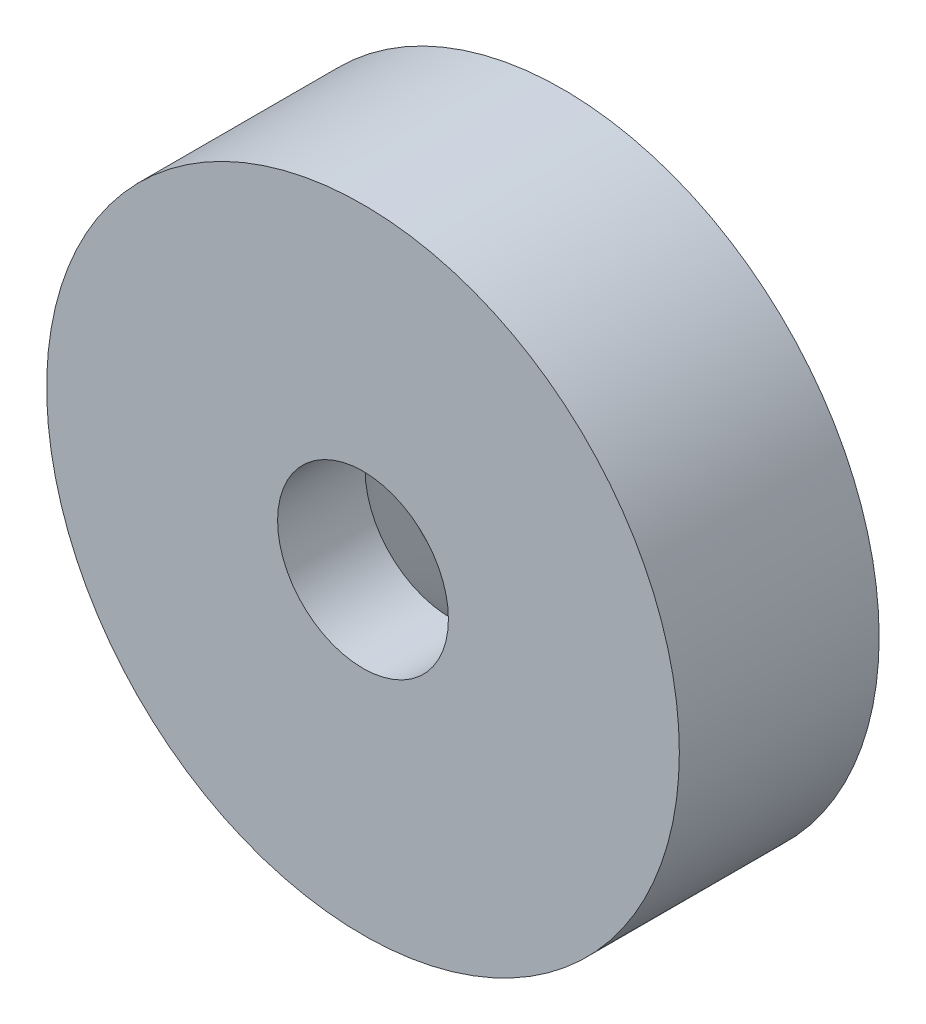
from build123d import *

# Parameters (mm, degrees)
SKETCH1_R           = 6
SKETCH1_R_2         = 1.62
BOSS_EXTRUDE1_DEPTH = 3.79
SKETCH2_R           = 3.75
CUT_EXTRUDE1_DEPTH  = 10
CUT_EXTRUDE1_DRAFT  = -45


with BuildPart() as part:
    # Sketch1 → Boss-Extrude1 (new body)
    with BuildSketch(Plane.XY):
        with Locations((5.056285212, 23.07899143)):
            Circle(SKETCH1_R)
        with Locations((5.056285212, 23.07899143)):
            Circle(SKETCH1_R_2, mode=Mode.SUBTRACT)
    extrude(amount=BOSS_EXTRUDE1_DEPTH)


with BuildPart() as cut_extrude1_tool:
    # Sketch2 → Cut-Extrude1 (with draft: the straight prism first)
    with BuildSketch(Plane(origin=(0, 0, 0), x_dir=(-1, 0, 0), z_dir=(0, 0, -1))):
        with Locations((-5.056285212, 23.07899143)):
            Circle(SKETCH2_R)
    extrude(amount=-CUT_EXTRUDE1_DEPTH)
    # Cut-Extrude1: the draft: its side faces are tilted about the plane it starts from
    cut_extrude1_sides = [cut_extrude1_tool.faces().sort_by_distance(p)[0] for p in [
        (8.806285212, 23.07899143, 5),
    ]]
    draft(cut_extrude1_sides, Plane(origin=(0, 0, 0), x_dir=(-1, 0, 0), z_dir=(0, 0, -1)), CUT_EXTRUDE1_DRAFT)


with BuildPart() as part_1:
    add(part.part)

    # Cut-Extrude1: cut by cut_extrude1_tool
    add(cut_extrude1_tool.part, mode=Mode.SUBTRACT)


solid = part_1.part
